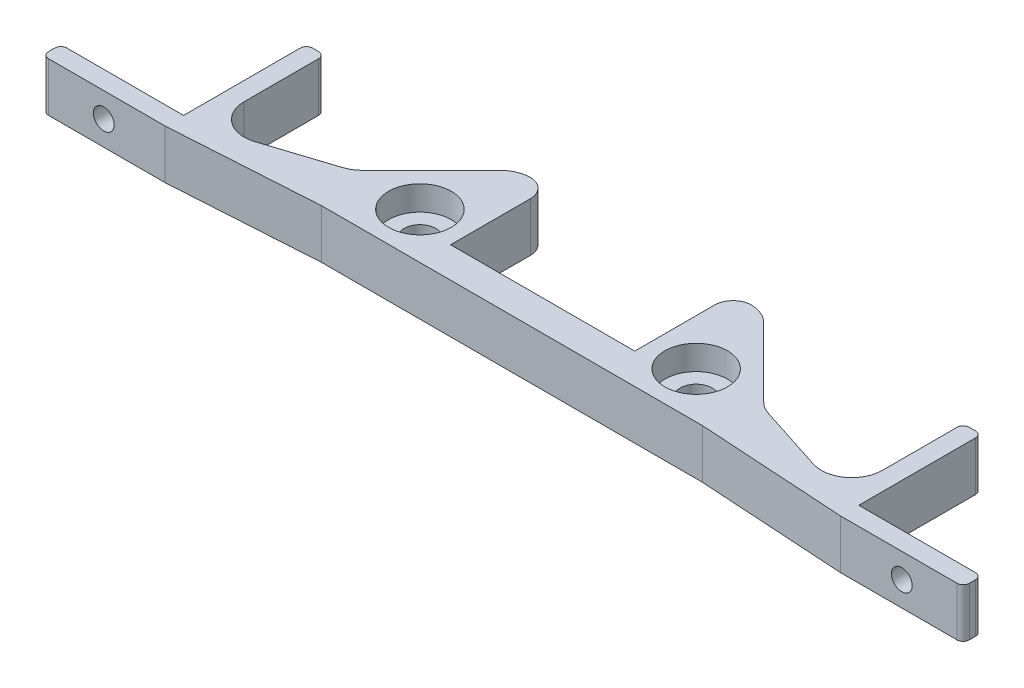
from build123d import *

# Parameters (mm, degrees)
ESQUISSE1_R             = 2.6
BOSS_EXTRU_1_DEPTH      = 8
ESQUISSE3_R             = 5.1
ENL_V_MAT_EXTRU_2_DEPTH = 4
ESQUISSE4_R             = 5.5
ESQUISSE4_R_2           = 4.5
ENL_V_MAT_EXTRU_3_DEPTH = 2
CONG_1_R                = 5
CONG_2_R                = 3
CONG_3_R                = 4
BOSS_EXTRU_2_DEPTH      = 8
CONG_4_R                = 5
ENL_V_MAT_EXTRU_4_REACH = 25
ESQUISSE6_R             = 1.7
CONG_5_R                = 1


with BuildPart() as part:
    # Esquisse1 → Boss.-Extru.1 (new body)
    with BuildSketch(Plane(origin=(0, 0, 0), x_dir=(1, 0, 0), z_dir=(0, 1, 0))):
        Polygon((-35, 0), (35, 0), (35, 6), (20, 21), (15, 21), (15, 5), (-15, 5), (-15, 21), (-20, 21), (-35, 6), align=None)
        with Locations((22.5, 7.5)):
            Circle(ESQUISSE1_R, mode=Mode.SUBTRACT)
        with Locations((-22.5, 7.5)):
            Circle(ESQUISSE1_R, mode=Mode.SUBTRACT)
    extrude(amount=BOSS_EXTRU_1_DEPTH)

    # Esquisse3 → Enlèv. mat.-Extru.2 (cut)
    with BuildSketch(Plane(origin=(0, 8, 0), x_dir=(1, 0, 0), z_dir=(0, 1, 0))):
        with Locations((-22.5, 7.5)):
            Circle(ESQUISSE3_R)
        with Locations((22.5, 7.5)):
            Circle(ESQUISSE3_R)
    extrude(amount=-ENL_V_MAT_EXTRU_2_DEPTH, mode=Mode.SUBTRACT)

    # Esquisse4 → Enlèv. mat.-Extru.3 (cut)
    with BuildSketch(Plane.XZ):
        with Locations((-22.5, -7.5)):
            Circle(ESQUISSE4_R)
        with Locations((-22.5, -7.5)):
            Circle(ESQUISSE4_R_2, mode=Mode.SUBTRACT)
        with Locations((22.5, -7.5)):
            Circle(ESQUISSE4_R)
        with Locations((22.5, -7.5)):
            Circle(ESQUISSE4_R_2, mode=Mode.SUBTRACT)
    extrude(amount=-ENL_V_MAT_EXTRU_3_DEPTH, mode=Mode.SUBTRACT)

    # Congé1
    cong_1_edges = [part.edges().sort_by_distance(p)[0] for p in [
        (-35, 4, -6),
        (-20, 4, -21),
        (20, 4, -21),
        (35, 4, -6),
    ]]
    fillet(cong_1_edges, radius=CONG_1_R)

    # Congé2
    cong_2_edges = [part.edges().sort_by_distance(p)[0] for p in [
        (-15, 4, -21),
        (15, 4, -21),
    ]]
    fillet(cong_2_edges, radius=CONG_2_R)

    # Congé3
    cong_3_edges = [part.edges().sort_by_distance(p)[0] for p in [
        (-35, 4, 0),
        (35, 4, 0),
    ]]
    fillet(cong_3_edges, radius=CONG_3_R)

    # Esquisse5 → Boss.-Extru.2 (add)
    with BuildSketch(Plane(origin=(0, 8, 0), x_dir=(1, 0, 0), z_dir=(0, 1, 0))):
        Polygon((30.997471486, 0), (54.997471486, -1.5), (74.997471486, -1.5), (74.997471486, 1.5), (54.997471486, 1.5), (54.997471486, 21.5), (51.997471486, 21.5), (51.997471486, 1.5), (33.535533906, 7.464466094), align=None)
        Polygon((-33.535533906, 7.464466094), (-30.997471486, 0), (-54.997471486, -1.5), (-74.997471486, -1.5), (-74.997471486, 1.5), (-54.997471486, 1.5), (-54.997471486, 21.5), (-51.997471486, 21.5), (-51.997471486, 1.5), align=None)
    extrude(amount=-BOSS_EXTRU_2_DEPTH)

    # Congé4
    cong_4_edges = [part.edges().sort_by_distance(p)[0] for p in [
        (51.997471486, 4, -1.5),
        (-51.997471486, 4, -1.5),
        (-33.535533906, 4, -7.464466094),
        (33.535533906, 4, -7.464466094),
    ]]
    fillet(cong_4_edges, radius=CONG_4_R)

    # Esquisse6 → Enlèv. mat.-Extru.4 (cut, up to next)
    with BuildSketch(Plane.XY.offset(1.5), mode=Mode.PRIVATE) as enl_v_mat_extru_4_sk1:
        with Locations((64.997471486, 4)):
            Circle(ESQUISSE6_R)
    enl_v_mat_extru_4_tool1 = extrude(enl_v_mat_extru_4_sk1.sketch, amount=-ENL_V_MAT_EXTRU_4_REACH, mode=Mode.PRIVATE) & part.part
    add(enl_v_mat_extru_4_tool1.solids().sort_by_distance((64.997471, 4, 1.5))[0], mode=Mode.SUBTRACT)
    # Esquisse6 → Enlèv. mat.-Extru.4 (cut, up to next)
    with BuildSketch(Plane.XY.offset(1.5), mode=Mode.PRIVATE) as enl_v_mat_extru_4_sk2:
        with Locations((-64.997471486, 4)):
            Circle(ESQUISSE6_R)
    enl_v_mat_extru_4_tool2 = extrude(enl_v_mat_extru_4_sk2.sketch, amount=-ENL_V_MAT_EXTRU_4_REACH, mode=Mode.PRIVATE) & part.part
    add(enl_v_mat_extru_4_tool2.solids().sort_by_distance((-64.997471, 4, 1.5))[0], mode=Mode.SUBTRACT)

    # Congé5
    cong_5_edges = [part.edges().sort_by_distance(p)[0] for p in [
        (51.997471486, 4, -21.5),
        (54.997471486, 4, -21.5),
        (74.997471486, 4, -1.5),
        (74.997471486, 4, 1.5),
        (-74.997471486, 4, 1.5),
        (-74.997471486, 4, -1.5),
        (-54.997471486, 4, -21.5),
        (-51.997471486, 4, -21.5),
    ]]
    fillet(cong_5_edges, radius=CONG_5_R)


solid = part.part
